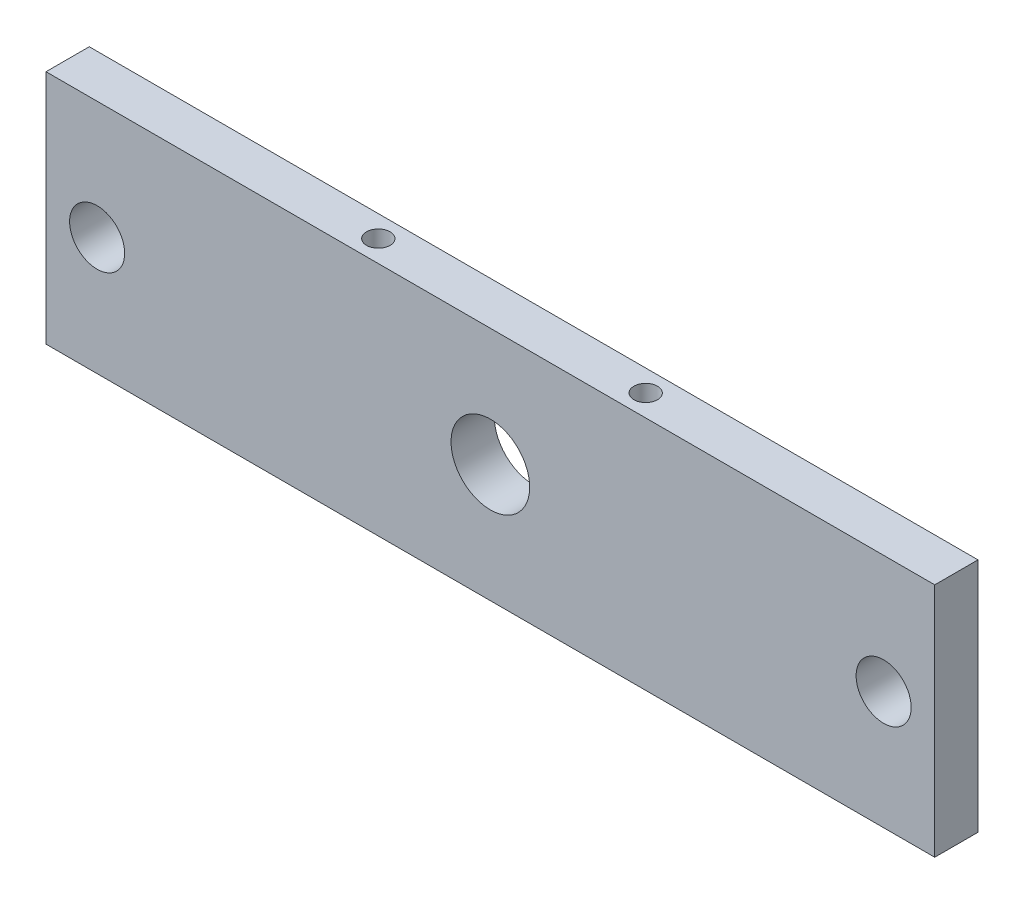
from build123d import *

# Parameters (mm, degrees)
ESBO_O1_W                  = 113
ESBO_O1_H                  = 30
ESBO_O1_R                  = 5
ESBO_O1_R_2                = 3.5
RESSALTO_EXTRUS_O1_DEPTH   = 5.5
ESBO_O2_R                  = 1.5
CORTE_EXTRUS_O1_DEPTH      = 110
CORTE_EXTRUS_O1_DEPTH_BACK = 77.5


with BuildPart() as part:
    # Esboço1 → Ressalto-extrusão1 (new body)
    with BuildSketch(Plane.XY):
        with Locations((-192.217741935, 41.451612903)):
            Rectangle(ESBO_O1_W, ESBO_O1_H)
        with Locations((-192.217741935, 41.451612903)):
            Circle(ESBO_O1_R, mode=Mode.SUBTRACT)
        with Locations((-242.217741935, 41.451612903)):
            Circle(ESBO_O1_R_2, mode=Mode.SUBTRACT)
        with Locations((-142.217741935, 41.451612903)):
            Circle(ESBO_O1_R_2, mode=Mode.SUBTRACT)
    extrude(amount=RESSALTO_EXTRUS_O1_DEPTH)

    # Esboço2 → Corte-extrusão1 (cut, two sides)
    with BuildSketch(Plane(origin=(0, 0, 0), x_dir=(1, 0, 0), z_dir=(0, 1, 0))) as corte_extrus_o1_sk:
        with Locations((-209.217741935, -2.75)):
            Circle(ESBO_O2_R)
        with Locations((-175.217741935, -2.75)):
            Circle(ESBO_O2_R)
    extrude(amount=CORTE_EXTRUS_O1_DEPTH, mode=Mode.SUBTRACT)
    extrude(corte_extrus_o1_sk.sketch, amount=-CORTE_EXTRUS_O1_DEPTH_BACK, mode=Mode.SUBTRACT)


solid = part.part
